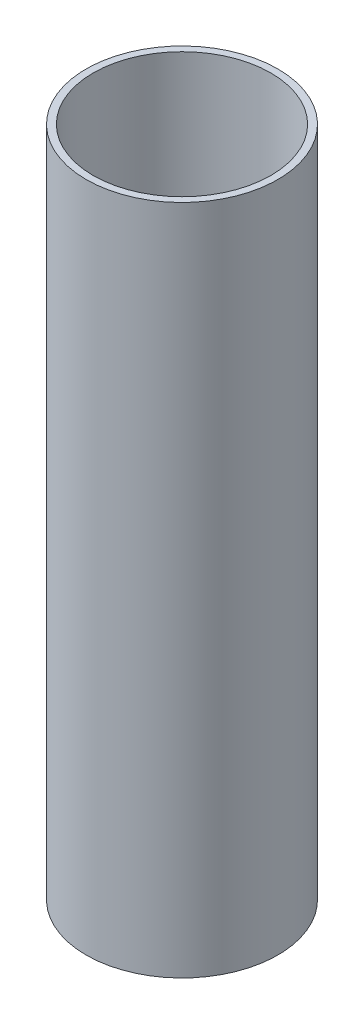
from build123d import *

# Parameters (mm, degrees)
SKETCH1_R           = 25.35
SKETCH1_R_2         = 23.5
BOSS_EXTRUDE1_DEPTH = 177.66


with BuildPart() as part:
    # Sketch1 → Boss-Extrude1 (new body)
    with BuildSketch(Plane(origin=(0, 0, 0), x_dir=(1, 0, 0), z_dir=(0, 1, 0))):
        Circle(SKETCH1_R)
        Circle(SKETCH1_R_2, mode=Mode.SUBTRACT)
    extrude(amount=BOSS_EXTRUDE1_DEPTH)


solid = part.part
